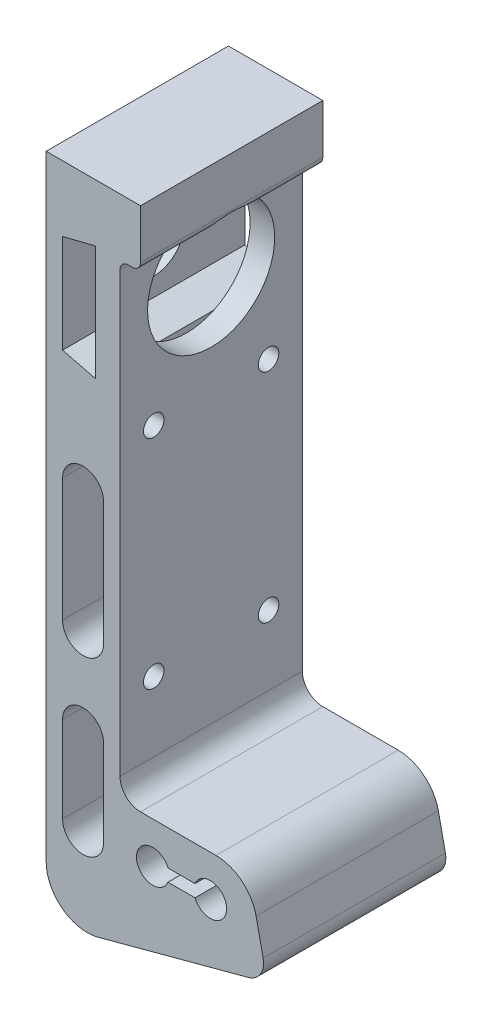
from build123d import *

# Parameters (mm, degrees)
BOSS_EXTRUDE1_DEPTH = 22.225
SKETCH2_R           = 2.5
SKETCH2_R_2         = 7.5
CUT_EXTRUDE5_DEPTH  = 18
CUT_EXTRUDE7_START  = 12
SKETCH2_8_R         = 15.5
CUT_EXTRUDE7_DEPTH  = 42


with BuildPart() as part:
    # Sketch1 → Boss-Extrude1 (new body, symmetric)
    with BuildSketch(Plane.XY):
        with BuildLine():
            Line((0, 28), (0, -122))
            ThreePointArc((0, -122), (3.91238571, -129.933533403), (12.588190451, -131.659258263))
            Line((12.588190451, -131.659258263), (49.294095226, -121.823940721))
            ThreePointArc((49.294095226, -121.823940721), (52.263200822, -119.606804413), (52.890738004, -115.954753136))
            Line((52.890738004, -115.954753136), (51.18308621, -107.920883092))
            ThreePointArc((51.18308621, -107.920883092), (47.694814113, -102.228540385), (41.401610203, -100))
            Line((41.401610203, -100), (23, -100))
            ThreePointArc((23, -100), (19.464466094, -98.535533906), (18, -95))
            Line((18, -95), (18, 12))
            ThreePointArc((18, 12), (18.585786438, 13.414213562), (20, 14))
            Line((20, 14), (21, 14))
            ThreePointArc((21, 14), (22.414213562, 14.585786438), (23, 16))
            Line((23, 16), (23, 28))
            Line((23, 28), (18, 28))
            Line((18, 28), (0, 28))
        make_face()
        with BuildLine():
            Line((4, -111), (4, -90))
            ThreePointArc((4, -90), (9, -85), (14, -90))
            Line((14, -90), (14, -111))
            ThreePointArc((14, -111), (9, -116), (4, -111))
        make_face(mode=Mode.SUBTRACT)
        with BuildLine():
            Line((4, -69), (4, -39))
            ThreePointArc((4, -39), (9, -34), (14, -39))
            Line((14, -39), (14, -69))
            ThreePointArc((14, -69), (9, -74), (4, -69))
        make_face(mode=Mode.SUBTRACT)
        with BuildLine():
            Line((29.708099244, -108.5), (36.291900756, -108.5))
            ThreePointArc((36.291900756, -108.5), (44, -110), (36.291900756, -111.5))
            Line((36.291900756, -111.5), (29.708099244, -111.5))
            ThreePointArc((29.708099244, -111.5), (22, -110), (29.708099244, -108.5))
        make_face(mode=Mode.SUBTRACT)
        Polygon((4, 12), (4, -12), (12, -14), (12, 14), align=None, mode=Mode.SUBTRACT)
    extrude(amount=BOSS_EXTRUDE1_DEPTH, both=True)

    # Sketch2 → Cut-Extrude5 (cut)
    with BuildSketch(Plane(origin=(0, 0, 0), x_dir=(0, 0, -1), z_dir=(1, 0, 0))):
        with Locations((14, -78)):
            Circle(SKETCH2_R)
        with Locations((-14, -78)):
            Circle(SKETCH2_R)
        with Locations((-14, -25)):
            Circle(SKETCH2_R)
        with Locations((14, -25)):
            Circle(SKETCH2_R)
        Circle(SKETCH2_R_2)
    extrude(amount=CUT_EXTRUDE5_DEPTH, mode=Mode.SUBTRACT)

    # Sketch2_8 → Cut-Extrude7 (cut, through all)
    with BuildSketch(Plane(origin=(0, 0, 0), x_dir=(0, 0, -1), z_dir=(1, 0, 0)).offset(CUT_EXTRUDE7_START)):
        Circle(SKETCH2_8_R)
    extrude(amount=CUT_EXTRUDE7_DEPTH, mode=Mode.SUBTRACT)


solid = part.part
